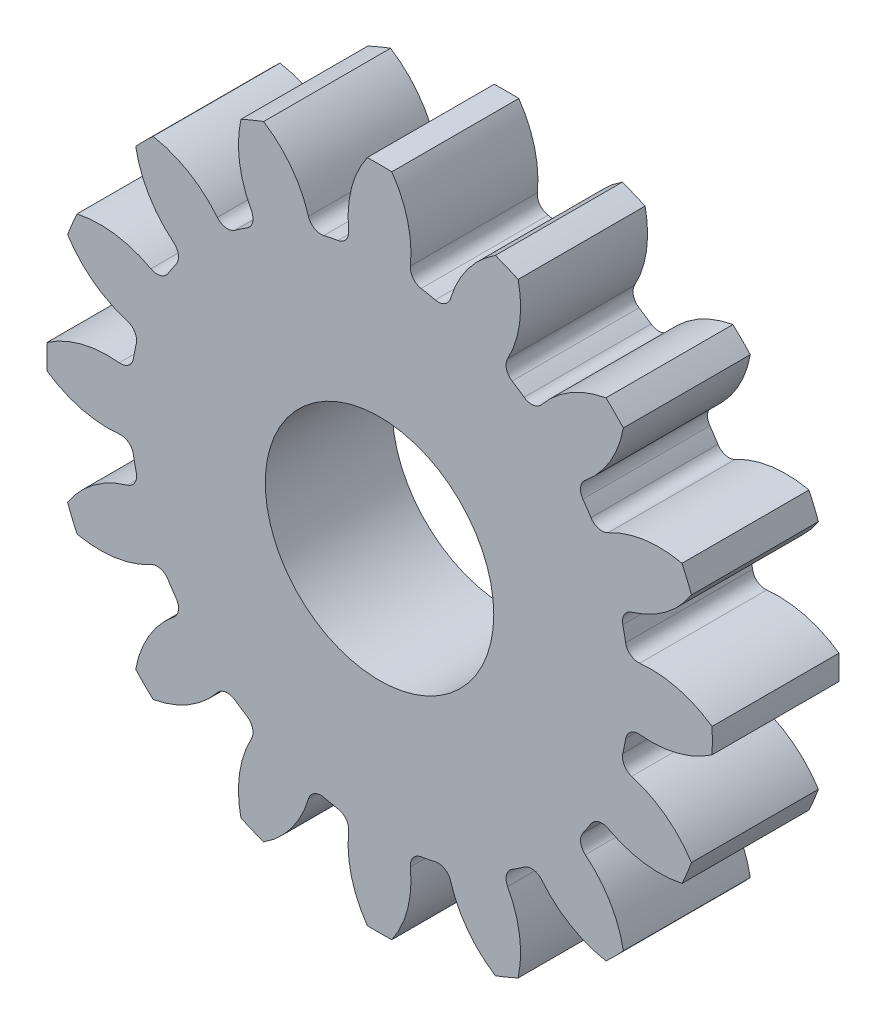
from build123d import *

# Parameters (mm, degrees)
ESQUISSE1_R                        = 1.15
BASE_EXTRUSION_DEPTH               = 2.5
BOSS_EXTRU_1_DEPTH                 = 4
CONG_1_R                           = 0.40775
R_P_TITION_CIRCULAIRE4_COUNT       = 16
CONG_1_OF_R_P_TITION_CIRCULAIRE4_R = 0.40775
ESQUISSE8_R                        = 3.6
ENL_V_MAT_EXTRU_1_DEPTH            = 16.358074586


with BuildPart() as part:
    # Esquisse1 → Base-Extrusion (new body)
    with BuildSketch(Plane.XY):
        Circle(ESQUISSE1_R)
    extrude(amount=BASE_EXTRUSION_DEPTH)

    # Esquisse3 → Boss.-Extru.1 (add)
    with BuildSketch(Plane.XY):
        with BuildLine():
            Line((-1.53414152, 7.712650249), (0, 0))
            Line((0, 0), (1.53414152, 7.712650249))
            ThreePointArc((1.53414152, 7.712650249), (1.222047708, 7.768214947), (0.907968022, 7.811156005))
            ThreePointArc((0.907968022, 7.811156005), (0.929201465, 9.199391503), (0.387682352, 10.477830281))
            ThreePointArc((0.387682352, 10.477830281), (0, 10.485), (-0.387682352, 10.477830281))
            ThreePointArc((-0.387682352, 10.477830281), (-0.929201465, 9.199391503), (-0.907968022, 7.811156005))
            ThreePointArc((-0.907968022, 7.811156005), (-1.222047708, 7.768214947), (-1.53414152, 7.712650249))
        make_face()
    boss_extru_1 = extrude(amount=BOSS_EXTRU_1_DEPTH)

    # Congé1
    cong_1_edges = [part.edges().sort_by_distance(p)[0] for p in [
        (0.907968022, 7.811156005, 2),
        (-0.907968022, 7.811156005, 2),
    ]]
    fillet(cong_1_edges, radius=CONG_1_R)

    # Répétition circulaire4: Boss.-Extru.1 ×16 about axis
    r_p_tition_circulaire4_axis = Axis((0, 0, 54), (0, 0, -1))
    for i in range(1, R_P_TITION_CIRCULAIRE4_COUNT):
        add(boss_extru_1.rotate(r_p_tition_circulaire4_axis, i * 360 / R_P_TITION_CIRCULAIRE4_COUNT))

    # Congé1 of Répétition circulaire4
    cong_1_of_r_p_tition_circulaire4_edges = [part.edges().sort_by_distance(p)[0] for p in [
        (3.828053063, 6.869102839, 2),
        (2.150346919, 7.564031477, 2),
        (6.165351726, 4.881291034, 2),
        (4.881291034, 6.165351726, 2),
        (7.564031477, 2.150346919, 2),
        (6.869102839, 3.828053063, 2),
        (7.811156005, -0.907968022, 2),
        (7.811156005, 0.907968022, 2),
        (6.869102839, -3.828053063, 2),
        (7.564031477, -2.150346919, 2),
        (4.881291034, -6.165351726, 2),
        (6.165351726, -4.881291034, 2),
        (2.150346919, -7.564031477, 2),
        (3.828053063, -6.869102839, 2),
        (-0.907968022, -7.811156005, 2),
        (0.907968022, -7.811156005, 2),
        (-3.828053063, -6.869102839, 2),
        (-2.150346919, -7.564031477, 2),
        (-6.165351726, -4.881291034, 2),
        (-4.881291034, -6.165351726, 2),
        (-7.564031477, -2.150346919, 2),
        (-6.869102839, -3.828053063, 2),
        (-7.811156005, 0.907968022, 2),
        (-7.811156005, -0.907968022, 2),
        (-6.869102839, 3.828053063, 2),
        (-7.564031477, 2.150346919, 2),
        (-4.881291034, 6.165351726, 2),
        (-6.165351726, 4.881291034, 2),
        (-2.150346919, 7.564031477, 2),
        (-3.828053063, 6.869102839, 2),
    ]]
    fillet(cong_1_of_r_p_tition_circulaire4_edges, radius=CONG_1_OF_R_P_TITION_CIRCULAIRE4_R)

    # Esquisse8 → Enlèv. mat.-Extru.1 (cut, through all)
    with BuildSketch(Plane.XY.offset(4)):
        Circle(ESQUISSE8_R)
    extrude(amount=-ENL_V_MAT_EXTRU_1_DEPTH, mode=Mode.SUBTRACT)


solid = part.part
